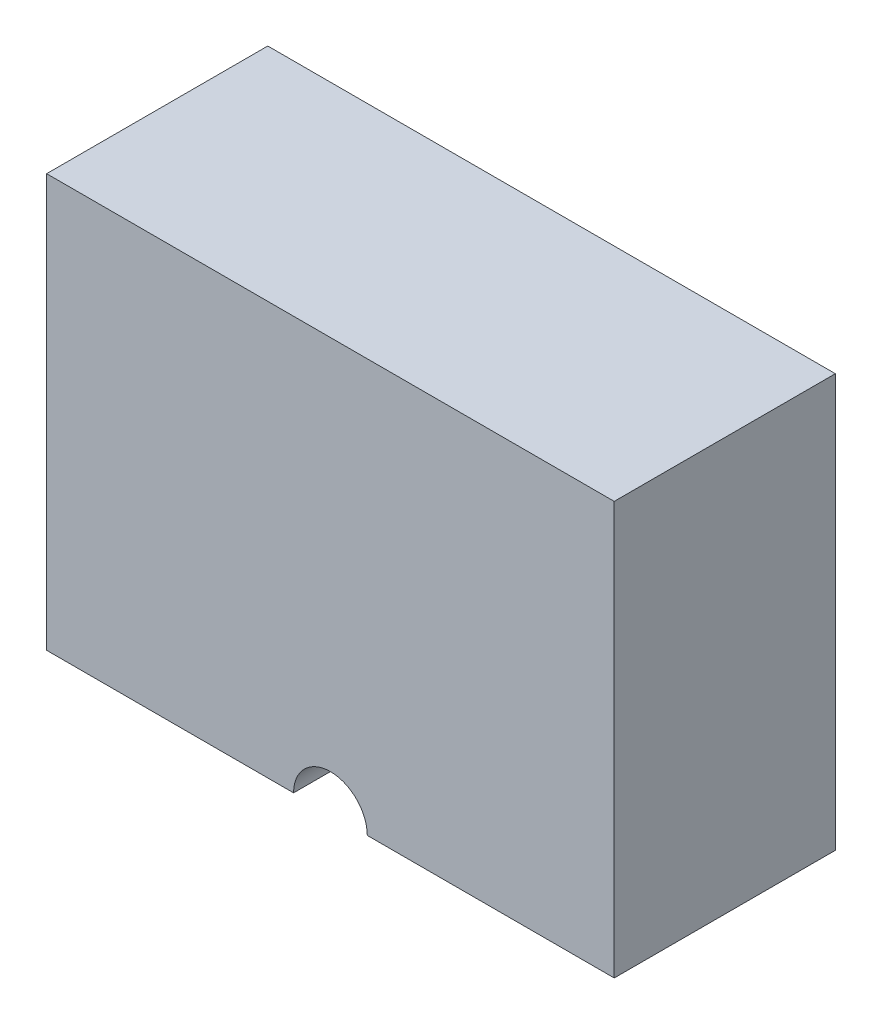
from build123d import *

# Parameters (mm, degrees)
SKETCH_1_W          = 7.7
SKETCH_1_H          = 5.6
EXTRUDE_1_DEPTH     = 3
SKETCH_2_R          = 0.5
CUT_EXTRUDE_2_DEPTH = 8.8
SKETCH_3_W          = 6.7
SKETCH_3_H          = 2
CUT_EXTRUDE_3_DEPTH = 5
EXTRUDE_2_DEPTH     = 5


with BuildPart() as part:
    # Эскиз1 → Бобышка-Вытянуть1 (new body)
    with BuildSketch(Plane.XY):
        Rectangle(SKETCH_1_W, SKETCH_1_H)
    extrude(amount=EXTRUDE_1_DEPTH)

    # Эскиз2 → Вырез-Вытянуть2 (cut)
    with BuildSketch(Plane.XY.offset(3)):
        with Locations((0, -2.8)):
            Circle(SKETCH_2_R)
    extrude(amount=-CUT_EXTRUDE_2_DEPTH, mode=Mode.SUBTRACT)

    # Эскиз3 → Вырез-Вытянуть3 (cut)
    with BuildSketch(Plane.XZ.offset(2.8)):
        with Locations((0, 1.5)):
            Rectangle(SKETCH_3_W, SKETCH_3_H)
    extrude(amount=-CUT_EXTRUDE_3_DEPTH, mode=Mode.SUBTRACT)

    # Эскиз4 → Бобышка-Вытянуть2 (add)
    with BuildSketch(Plane.XZ.offset(-2.2)):
        Polygon((-3.35, 2.5), (-2.35, 0.5), (-3.35, 0.5), align=None)
        Polygon((3.35, 2.5), (3.35, 0.5), (2.35, 0.5), align=None)
    extrude(amount=EXTRUDE_2_DEPTH)


solid = part.part
